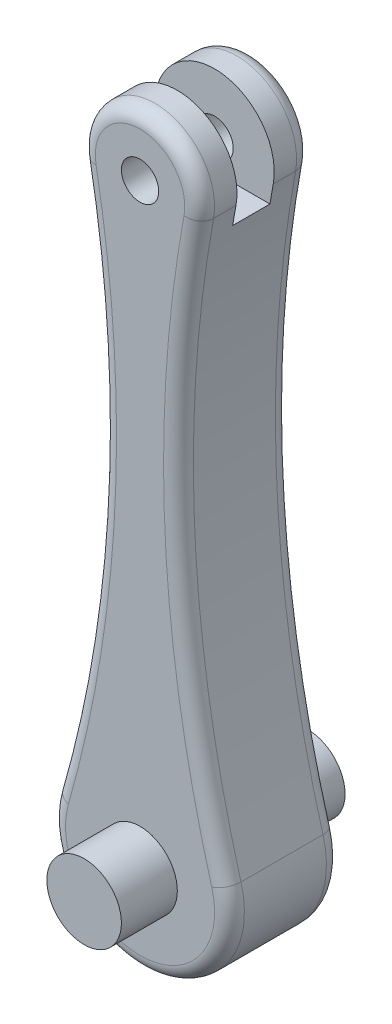
from build123d import *

# Parameters (mm, degrees)
SKETCH1_R                = 2.5
BOSS_EXTRUDE1_DEPTH      = 15
FILLET4_R                = 2
SKETCH9_W                = 5
SKETCH9_H                = 12
CUT_EXTRUDE1_DEPTH       = 13.0000001
CUT_EXTRUDE1_DEPTH_BACK  = 13.0000001
SKETCH10_R               = 5
BOSS_EXTRUDE2_DEPTH      = 22.5
BOSS_EXTRUDE2_DEPTH_BACK = 7.5


with BuildPart() as part:
    # Sketch1 → Boss-Extrude1 (new body)
    with BuildSketch(Plane.XY):
        with BuildLine():
            ThreePointArc((7.868400372, 78.554913295), (0, 88), (-7.868400372, 78.554913295))
            ThreePointArc((-7.868400372, 78.554913295), (-5.349774026, 40.71787649), (-11.535875122, 3.305084746))
            ThreePointArc((-11.535875122, 3.305084746), (0, -12), (11.535875122, 3.305084746))
            ThreePointArc((11.535875122, 3.305084746), (5.349774026, 40.71787649), (7.868400372, 78.554913295))
        make_face()
        with Locations((0, 80)):
            Circle(SKETCH1_R, mode=Mode.SUBTRACT)
    extrude(amount=BOSS_EXTRUDE1_DEPTH)

    # Fillet4
    fillet4_edges = [part.edges().sort_by_distance(p)[0] for p in [
        (5.349774026, 40.71787649, 15),
        (0, 88, 15),
        (-5.349774026, 40.71787649, 15),
        (0, 88, 0),
        (5.349774026, 40.71787649, 0),
        (0, -12, 0),
        (-5.349774026, 40.71787649, 0),
        (0, -12, 15),
    ]]
    fillet(fillet4_edges, radius=FILLET4_R)

    # Sketch9 → Cut-Extrude1 (cut, two sides)
    with BuildSketch(Plane(origin=(0, 0, 0), x_dir=(0, 0, -1), z_dir=(1, 0, 0))) as cut_extrude1_sk:
        with Locations((-7.5, 82.000003295)):
            Rectangle(SKETCH9_W, SKETCH9_H)
    extrude(amount=CUT_EXTRUDE1_DEPTH, mode=Mode.SUBTRACT)
    extrude(cut_extrude1_sk.sketch, amount=-CUT_EXTRUDE1_DEPTH_BACK, mode=Mode.SUBTRACT)

    # Sketch10 → Boss-Extrude2 (add, two sides)
    with BuildSketch(Plane.XY) as boss_extrude2_sk:
        Circle(SKETCH10_R)
    extrude(amount=BOSS_EXTRUDE2_DEPTH)
    extrude(boss_extrude2_sk.sketch, amount=-BOSS_EXTRUDE2_DEPTH_BACK)


solid = part.part
